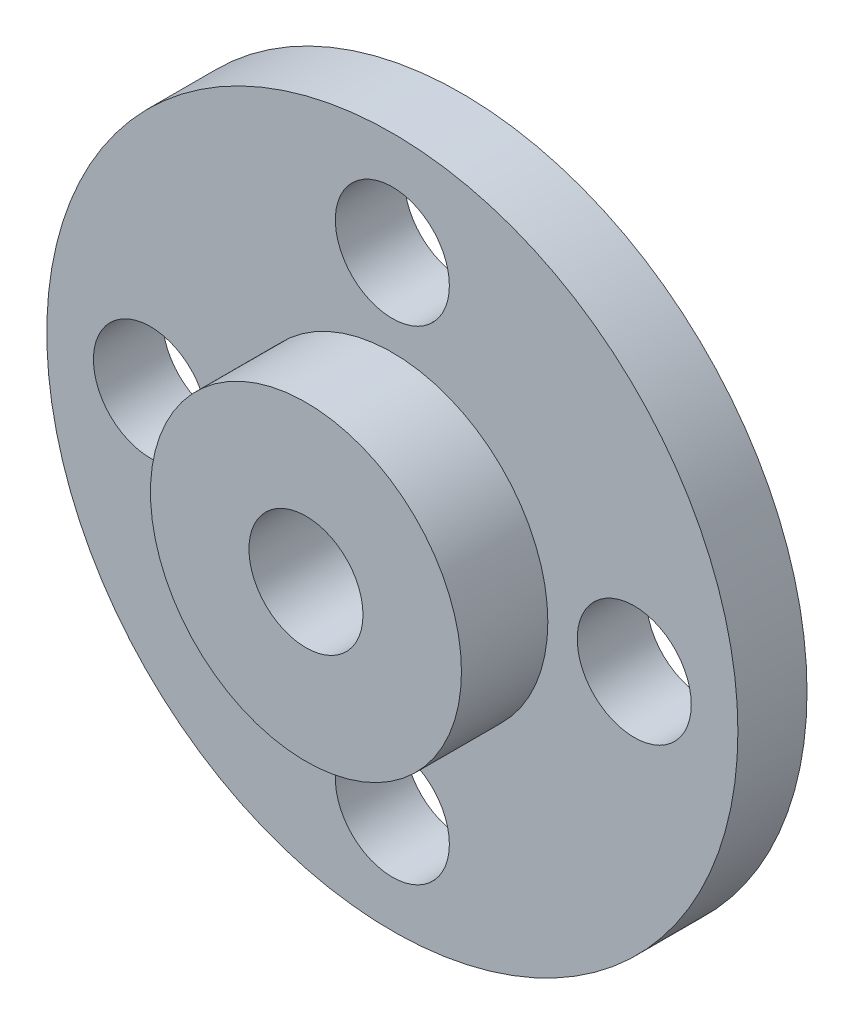
from build123d import *

# Parameters (mm, degrees)
SKETCH_1_R          = 10
EXTRUDE_1_DEPTH     = 2
SKETCH_2_R          = 4.5
EXTRUDE_2_DEPTH     = 2.5
SKETCH_3_R          = 1.65
CUT_EXTRUDE_1_DEPTH = 8.5
SKETCH_4_R          = 1.65
CUT_EXTRUDE_2_DEPTH = 8.5


with BuildPart() as part:
    # 草图1 → 凸台-拉伸1 (new body)
    with BuildSketch(Plane.XY):
        Circle(SKETCH_1_R)
    extrude(amount=EXTRUDE_1_DEPTH)

    # 草图2 → 凸台-拉伸2 (add)
    with BuildSketch(Plane.XY.offset(2)):
        Circle(SKETCH_2_R)
    extrude(amount=EXTRUDE_2_DEPTH)

    # 草图3 → 切除-拉伸1 (cut)
    with BuildSketch(Plane.XY.offset(4.5)):
        Circle(SKETCH_3_R)
    extrude(amount=-CUT_EXTRUDE_1_DEPTH, mode=Mode.SUBTRACT)

    # 草图4 → 切除-拉伸2 (cut)
    with BuildSketch(Plane.XY.offset(2)):
        with Locations((0, 7)):
            Circle(SKETCH_4_R)
        with Locations((7, 0)):
            Circle(SKETCH_4_R)
        with Locations((0, -7)):
            Circle(SKETCH_4_R)
        with Locations((-7, 0)):
            Circle(SKETCH_4_R)
    extrude(amount=-CUT_EXTRUDE_2_DEPTH, mode=Mode.SUBTRACT)


solid = part.part
